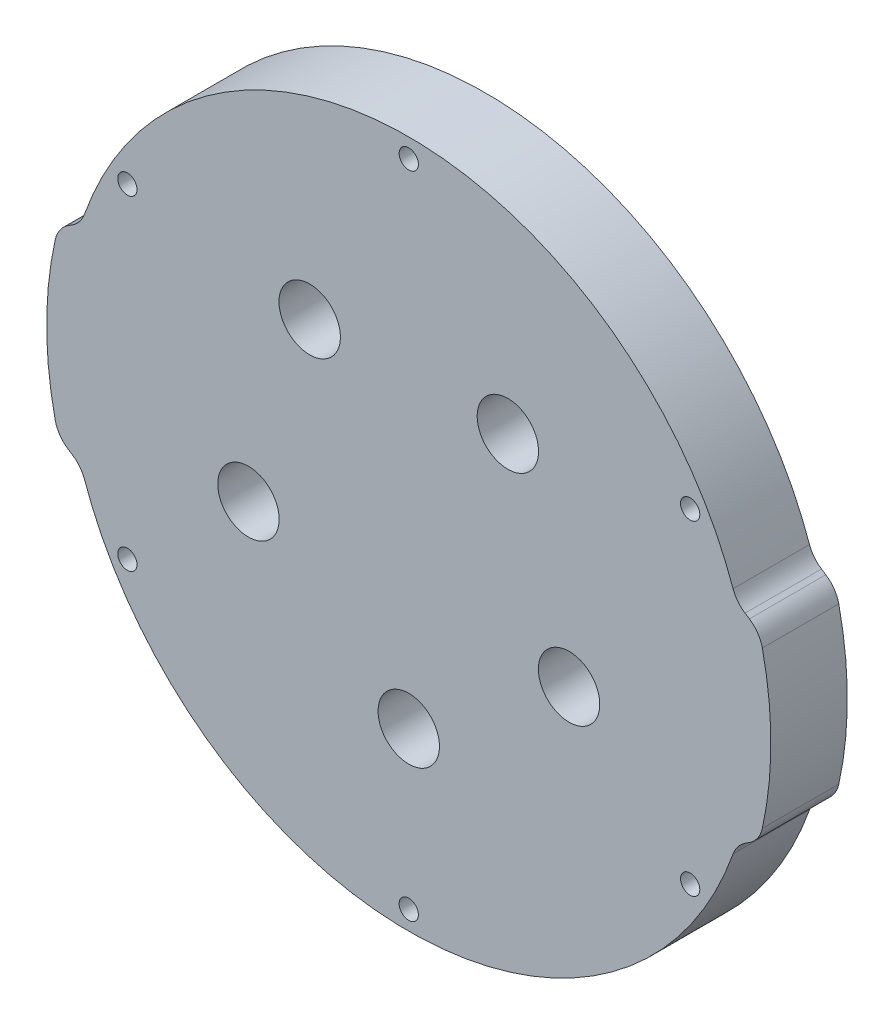
from build123d import *

# Parameters (mm, degrees)
SKETCH1_R           = 1.6
BOSS_EXTRUDE1_DEPTH = 12.7
SKETCH6_R           = 5.1
CUT_EXTRUDE2_DEPTH  = 13.7
FILLET1_R           = 5


with BuildPart() as part:
    # Sketch1 → Boss-Extrude1 (new body)
    with BuildSketch(Plane.XY):
        with BuildLine():
            Line((54.404710274, 17.5), (58.249656651, 15))
            ThreePointArc((58.249656651, 15), (60.15, 0), (58.249656651, -15))
            Line((58.249656651, -15), (54.404710274, -17.5))
            ThreePointArc((54.404710274, -17.5), (0, -57.15), (-54.404710274, -17.5))
            Line((-54.404710274, -17.5), (-58.249656651, -15))
            ThreePointArc((-58.249656651, -15), (-60.15, 0), (-58.249656651, 15))
            Line((-58.249656651, 15), (-54.404710274, 17.5))
            ThreePointArc((-54.404710274, 17.5), (0, 57.15), (54.404710274, 17.5))
        make_face()
        with Locations((0, 53.975)):
            Circle(SKETCH1_R, mode=Mode.SUBTRACT)
        with Locations((46.743721169, 26.9875)):
            Circle(SKETCH1_R, mode=Mode.SUBTRACT)
        with Locations((46.743721169, -26.9875)):
            Circle(SKETCH1_R, mode=Mode.SUBTRACT)
        with Locations((0, -53.975)):
            Circle(SKETCH1_R, mode=Mode.SUBTRACT)
        with Locations((-46.743721169, -26.9875)):
            Circle(SKETCH1_R, mode=Mode.SUBTRACT)
        with Locations((-46.743721169, 26.9875)):
            Circle(SKETCH1_R, mode=Mode.SUBTRACT)
    extrude(amount=BOSS_EXTRUDE1_DEPTH)

    # Sketch6 → Cut-Extrude2 (cut, through all)
    with BuildSketch(Plane(origin=(0, 0, 0), x_dir=(-1, 0, 0), z_dir=(0, 0, -1))):
        with Locations((16.457987064, 22.652475842)):
            Circle(SKETCH6_R)
        with Locations((-26.629582456, -8.652475842)):
            Circle(SKETCH6_R)
        with Locations((26.629582456, -8.652475842)):
            Circle(SKETCH6_R)
        with Locations((-16.457987064, 22.652475842)):
            Circle(SKETCH6_R)
        with Locations((0, -28)):
            Circle(SKETCH6_R)
    extrude(amount=-CUT_EXTRUDE2_DEPTH, mode=Mode.SUBTRACT)

    # Fillet1
    fillet1_edges = [part.edges().sort_by_distance(p)[0] for p in [
        (54.404710274, 17.5, 6.35),
        (58.249656651, 15, 6.35),
        (58.249656651, -15, 6.35),
        (54.404710274, -17.5, 6.35),
        (-54.404710274, -17.5, 6.35),
        (-58.249656651, -15, 6.35),
        (-58.249656651, 15, 6.35),
        (-54.404710274, 17.5, 6.35),
    ]]
    fillet(fillet1_edges, radius=FILLET1_R)


solid = part.part
